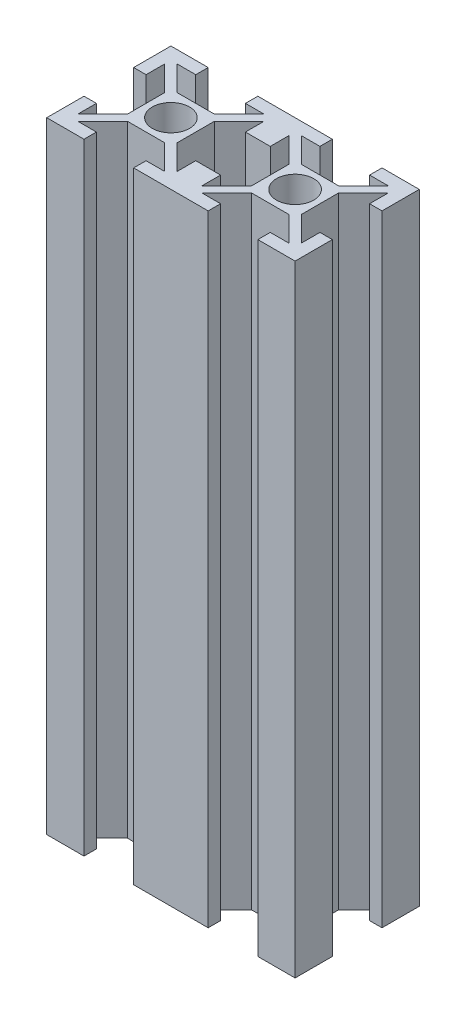
from build123d import *

# Parameters (mm, degrees)
F_2020_SKETCH_R     = 3
BOSS_EXTRUDE1_DEPTH = 100


with BuildPart() as part:
    # 2020 sketch → Boss-Extrude1 (new body)
    with BuildSketch(Plane(origin=(0, 0, 0), x_dir=(1, 0, 0), z_dir=(0, 1, 0))):
        Polygon((-4, 10), (-4, 8), (-7, 8), (-3, 4), (3, 4), (7, 8), (4, 8), (4, 10), (10, 10), (10, 4), (8, 4), (8, 7), (4, 3), (4, -3), (8, -7), (8, -4), (10, -4), (10, -10), (4, -10), (4, -8), (7, -8), (3, -4), (-3, -4), (-7, -8), (-4, -8), (-4, -10), (-10, -10), (-10, -4), (-8, -4), (-8, -7), (-4, -3), (-4, 3), (-8, 7), (-8, 4), (-10, 4), (-10, 10), align=None)
        Circle(F_2020_SKETCH_R, mode=Mode.SUBTRACT)
    boss_extrude1 = extrude(amount=BOSS_EXTRUDE1_DEPTH)

    # Mirror1: Boss-Extrude1 across plane
    add(boss_extrude1.mirror(Plane(origin=(10, 100, 4), x_dir=(0, 0, 1), z_dir=(1, 0, 0))))


solid = part.part
